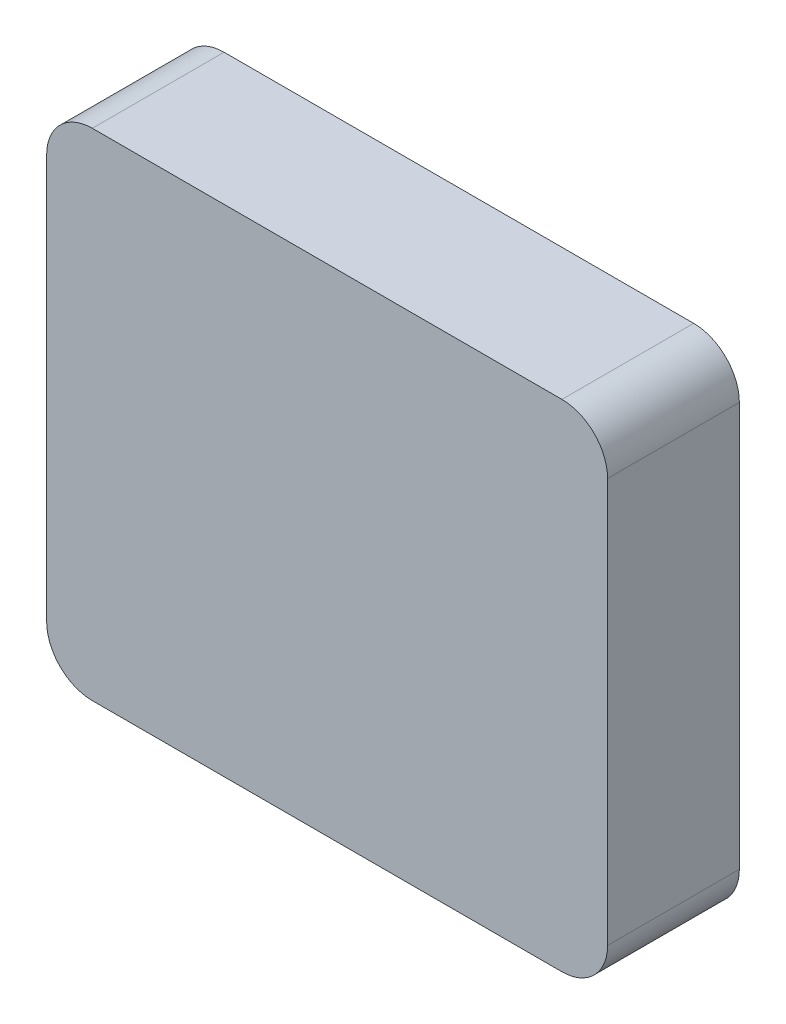
from build123d import *

# Parameters (mm, degrees)
SKETCH1_W           = 350
SKETCH1_H           = 300
BOSS_EXTRUDE1_DEPTH = 100
BOSS_EXTRUDE2_DEPTH = 1


with BuildPart() as part:
    # Sketch1 → Boss-Extrude1 (new body)
    with BuildSketch(Plane.XY):
        with BuildLine():
            Line((-355, 340), (5, 340))
            ThreePointArc((5, 340), (29.748737342, 329.748737342), (40, 305))
            Line((40, 305), (40, -5))
            ThreePointArc((40, -5), (29.748737342, -29.748737342), (5, -40))
            Line((5, -40), (-355, -40))
            ThreePointArc((-355, -40), (-379.748737342, -29.748737342), (-390, -5))
            Line((-390, -5), (-390, 305))
            ThreePointArc((-390, 305), (-379.748737342, 329.748737342), (-355, 340))
        make_face()
        with Locations((-175, 150)):
            Rectangle(SKETCH1_W, SKETCH1_H, mode=Mode.SUBTRACT)
    extrude(amount=BOSS_EXTRUDE1_DEPTH)

    # Sketch2 → Boss-Extrude2 (add)
    with BuildSketch(Plane.XY.offset(100)):
        with BuildLine():
            Line((-355, -40), (5, -40))
            ThreePointArc((5, -40), (29.748737342, -29.748737342), (40, -5))
            Line((40, -5), (40, 305))
            ThreePointArc((40, 305), (29.748737342, 329.748737342), (5, 340))
            Line((5, 340), (-355, 340))
            ThreePointArc((-355, 340), (-379.748737342, 329.748737342), (-390, 305))
            Line((-390, 305), (-390, -5))
            ThreePointArc((-390, -5), (-379.748737342, -29.748737342), (-355, -40))
        make_face()
    extrude(amount=BOSS_EXTRUDE2_DEPTH)


solid = part.part
